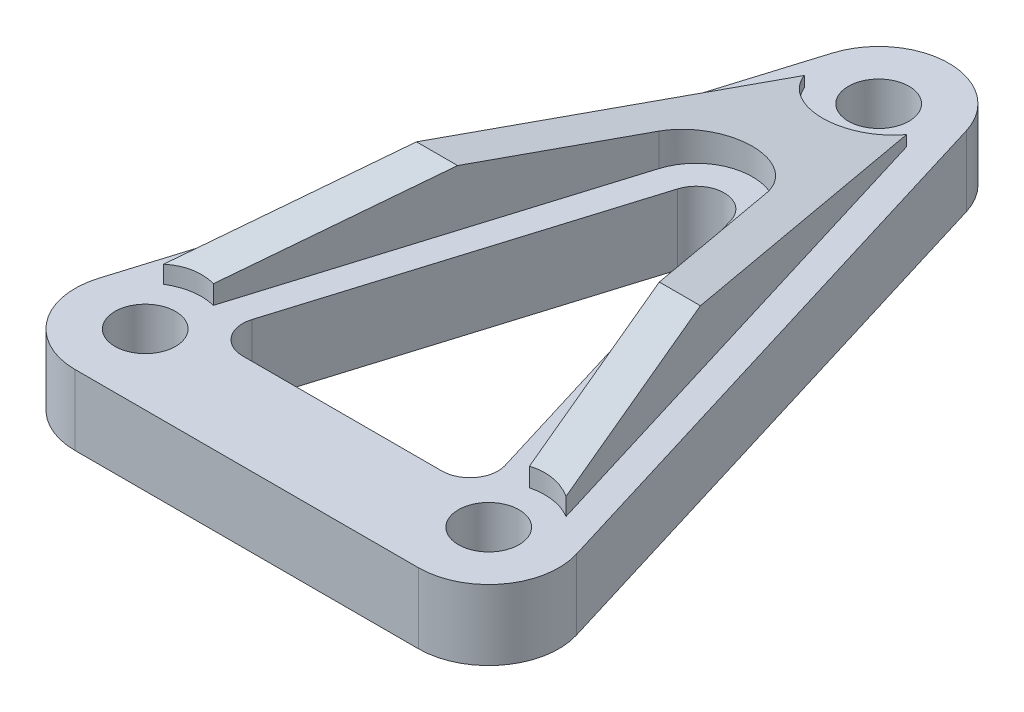
from build123d import *

# Parameters (mm, degrees)
SKETCH1_R        = 1.3716
BODY_DEPTH       = 1.5875
SKETCH2_R        = 1.3716
RIB_DEPTH        = 3.175
ANGLE_DEPTH      = 11.940559309
ANGLE_DEPTH_BACK = 11.940559309
BOLT_START       = -3.175
SKETCH5_R        = 2.54
BOLT_HOLE_DEPTH  = 2.54


with BuildPart() as part:
    # Sketch1 → Body (new body, symmetric)
    with BuildSketch(Plane(origin=(0, 0, 0), x_dir=(1, 0, 0), z_dir=(0, 1, 0))):
        with BuildLine():
            Line((-3.0362676, 0.928280162), (-10.801826909, -24.471719838))
            ThreePointArc((-10.801826909, -24.471719838), (-10.317804842, -27.288562348), (-7.765559309, -28.575))
            Line((-7.765559309, -28.575), (7.765559309, -28.575))
            ThreePointArc((7.765559309, -28.575), (10.317804842, -27.288562348), (10.801826909, -24.471719838))
            Line((10.801826909, -24.471719838), (3.0362676, 0.928280162))
            ThreePointArc((3.0362676, 0.928280162), (0, 3.175), (-3.0362676, 0.928280162))
        make_face()
        Circle(SKETCH1_R, mode=Mode.SUBTRACT)
        with Locations((-7.765559309, -25.4)):
            Circle(SKETCH1_R, mode=Mode.SUBTRACT)
        with Locations((7.765559309, -25.4)):
            Circle(SKETCH1_R, mode=Mode.SUBTRACT)
        with BuildLine():
            Line((-1.21450704, -7.88188057), (-5.719084006, -22.615687935))
            ThreePointArc((-5.719084006, -22.615687935), (-5.525475179, -23.742424939), (-4.504576966, -24.257))
            Line((-4.504576966, -24.257), (4.504576966, -24.257))
            ThreePointArc((4.504576966, -24.257), (5.525475179, -23.742424939), (5.719084006, -22.615687935))
            Line((5.719084006, -22.615687935), (1.21450704, -7.88188057))
            ThreePointArc((1.21450704, -7.88188057), (0, -6.983192635), (-1.21450704, -7.88188057))
        make_face(mode=Mode.SUBTRACT)
    extrude(amount=BODY_DEPTH, both=True)

    # Sketch2 → Rib (add)
    with BuildSketch(Plane(origin=(0, 1.5875, 0), x_dir=(1, 0, 0), z_dir=(0, 1, 0))):
        with BuildLine():
            Line((-7.487715721, -24.056836011), (-6.933591046, -22.24437587))
            Line((-6.933591046, -22.24437587), (-2.42901408, -7.510568505))
            ThreePointArc((-2.42901408, -7.510568505), (0, -5.713192635), (2.42901408, -7.510568505))
            Line((2.42901408, -7.510568505), (6.933591046, -22.24437587))
            Line((6.933591046, -22.24437587), (7.487715721, -24.056836011))
            ThreePointArc((7.487715721, -24.056836011), (8.631641376, -24.336426583), (9.137159309, -25.4))
            ThreePointArc((9.137159309, -25.4), (8.904756482, -26.163882426), (8.286304306, -26.668901576))
            Line((8.286304306, -26.668901576), (8.442739025, -27.180576489))
            ThreePointArc((8.442739025, -27.180576489), (9.476466758, -26.237747397), (9.587319869, -24.843031903))
            Line((9.587319869, -24.843031903), (1.82176056, 0.556968097))
            ThreePointArc((1.82176056, 0.556968097), (0, 1.905), (-1.82176056, 0.556968097))
            Line((-1.82176056, 0.556968097), (-9.587319869, -24.843031903))
            ThreePointArc((-9.587319869, -24.843031903), (-9.476466758, -26.237747397), (-8.442739025, -27.180576489))
            Line((-8.442739025, -27.180576489), (-8.286304306, -26.668901576))
            ThreePointArc((-8.286304306, -26.668901576), (-9.077226912, -24.99898297), (-7.487715721, -24.056836011))
        make_face()
        Circle(SKETCH2_R, mode=Mode.SUBTRACT)
    extrude(amount=RIB_DEPTH)

    # Sketch6 → Angle (cut, two sides)
    with BuildSketch(Plane(origin=(0, 0, 0), x_dir=(0, 0, -1), z_dir=(1, 0, 0))) as angle_sk:
        Polygon((-14.480576489, 4.1275), (2.051640081, 1.5875), (2.051640081, 8.789734229), (-27.180576489, 8.789734229), (-27.180576489, 1.5875), align=None)
    extrude(amount=ANGLE_DEPTH, mode=Mode.SUBTRACT)
    extrude(angle_sk.sketch, amount=-ANGLE_DEPTH_BACK, mode=Mode.SUBTRACT)

    # Sketch5 → Bolt hole (cut)
    with BuildSketch(Plane.XZ.offset(1.5875).offset(BOLT_START)):
        Circle(SKETCH5_R)
        with Locations((7.765559309, 25.4)):
            Circle(SKETCH5_R)
        with Locations((-7.765559309, 25.4)):
            Circle(SKETCH5_R)
    extrude(amount=-BOLT_HOLE_DEPTH, mode=Mode.SUBTRACT)


solid = part.part
